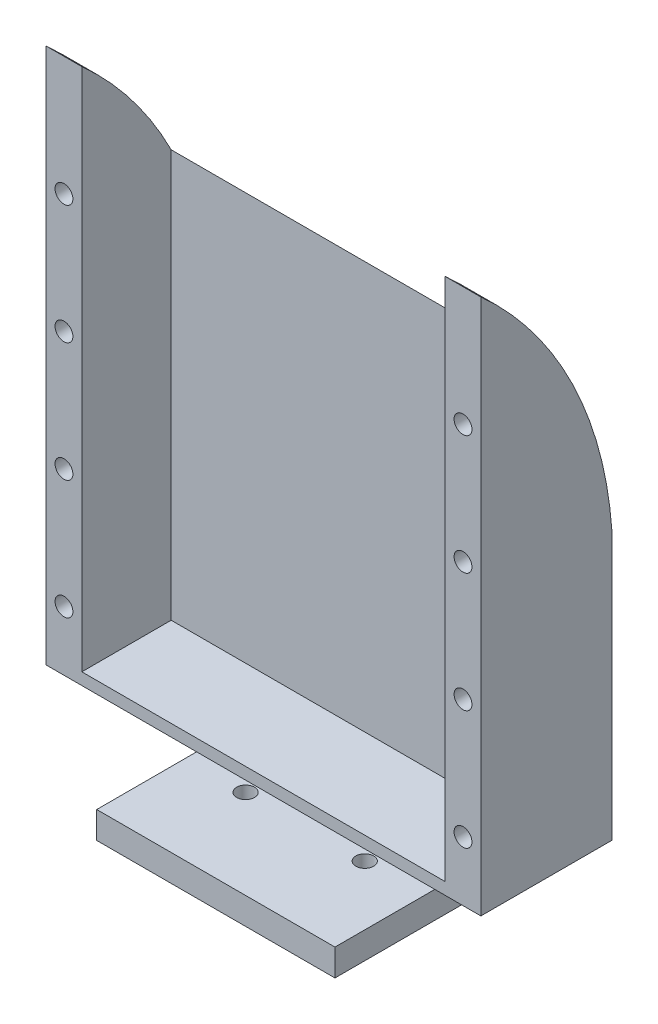
from build123d import *

# Parameters (mm, degrees)
SKETCH_1_W          = 40
SKETCH_1_H          = 30
SKETCH_1_R          = 1.5
EXTRUDE_1_DEPTH     = 4.5
SKETCH_3_R          = 1.5
EXTRUDE_2_DEPTH     = 7
SKETCH_4_R          = 3.5
CUT_EXTRUDE_2_DEPTH = 3
EXTRUDE_3_DEPTH     = 15
SKETCH_7_R          = 1.5
CUT_EXTRUDE_3_DEPTH = 8
CUT_EXTRUDE_4_DEPTH = 74


with BuildPart() as part:
    # 草图1 → 凸台-拉伸1 (new body)
    with BuildSketch(Plane(origin=(0, 0, 0), x_dir=(1, 0, 0), z_dir=(0, 1, 0))):
        Rectangle(SKETCH_1_W, SKETCH_1_H)
        with Locations((-10, 0)):
            Circle(SKETCH_1_R, mode=Mode.SUBTRACT)
        with Locations((10, 0)):
            Circle(SKETCH_1_R, mode=Mode.SUBTRACT)
    extrude(amount=EXTRUDE_1_DEPTH)

    # 草图3 → 凸台-拉伸2 (add)
    with BuildSketch(Plane(origin=(0, 0, -15), x_dir=(-1, 0, 0), z_dir=(0, 0, -1))):
        Polygon((-20, 4.5), (-20, 13.27), (-36.5, 13.27), (-36.5, 103.27), (36.5, 103.27), (36.5, 13.27), (20, 13.27), (20, 4.5), align=None)
        with Locations((-10, 8.27)):
            Circle(SKETCH_3_R, mode=Mode.SUBTRACT)
        with Locations((10, 8.27)):
            Circle(SKETCH_3_R, mode=Mode.SUBTRACT)
    extrude(amount=-EXTRUDE_2_DEPTH)

    # 草图4 → 切除-拉伸2 (cut)
    with BuildSketch(Plane.XY.offset(-8)):
        with Locations((-10, 8.27)):
            Circle(SKETCH_4_R)
        with Locations((10, 8.27)):
            Circle(SKETCH_4_R)
    extrude(amount=-CUT_EXTRUDE_2_DEPTH, mode=Mode.SUBTRACT)

    # 草图6 → 凸台-拉伸3 (add)
    with BuildSketch(Plane.XY.offset(-8)):
        Polygon((-36.5, 103.27), (-36.5, 13.27), (36.5, 13.27), (36.5, 103.27), (30.5, 103.27), (30.5, 15.27), (-30.5, 15.27), (-30.5, 103.27), align=None)
    extrude(amount=EXTRUDE_3_DEPTH)

    # 草图7 → 切除-拉伸3 (cut)
    with BuildSketch(Plane.XY.offset(7)):
        with Locations((-33.5, 83.27)):
            Circle(SKETCH_7_R)
        with Locations((-33.5, 63.27)):
            Circle(SKETCH_7_R)
        with Locations((-33.5, 43.27)):
            Circle(SKETCH_7_R)
        with Locations((33.5, 43.27)):
            Circle(SKETCH_7_R)
        with Locations((33.5, 63.27)):
            Circle(SKETCH_7_R)
        with Locations((33.5, 83.27)):
            Circle(SKETCH_7_R)
        with Locations((-33.5, 23.27)):
            Circle(SKETCH_7_R)
        with Locations((33.5, 23.27)):
            Circle(SKETCH_7_R)
    extrude(amount=-CUT_EXTRUDE_3_DEPTH, mode=Mode.SUBTRACT)

    # 草图9 → 切除-拉伸4 (cut, through all)
    with BuildSketch(Plane.ZY.offset(36.5)):
        with BuildLine():
            Line((-15, 58.27), (-15, 103.27))
            Line((-15, 103.27), (7, 103.27))
            ThreePointArc((7, 103.27), (-8.383194963, 82.912895315), (-15, 58.27))
        make_face()
    extrude(amount=-CUT_EXTRUDE_4_DEPTH, mode=Mode.SUBTRACT)


solid = part.part
